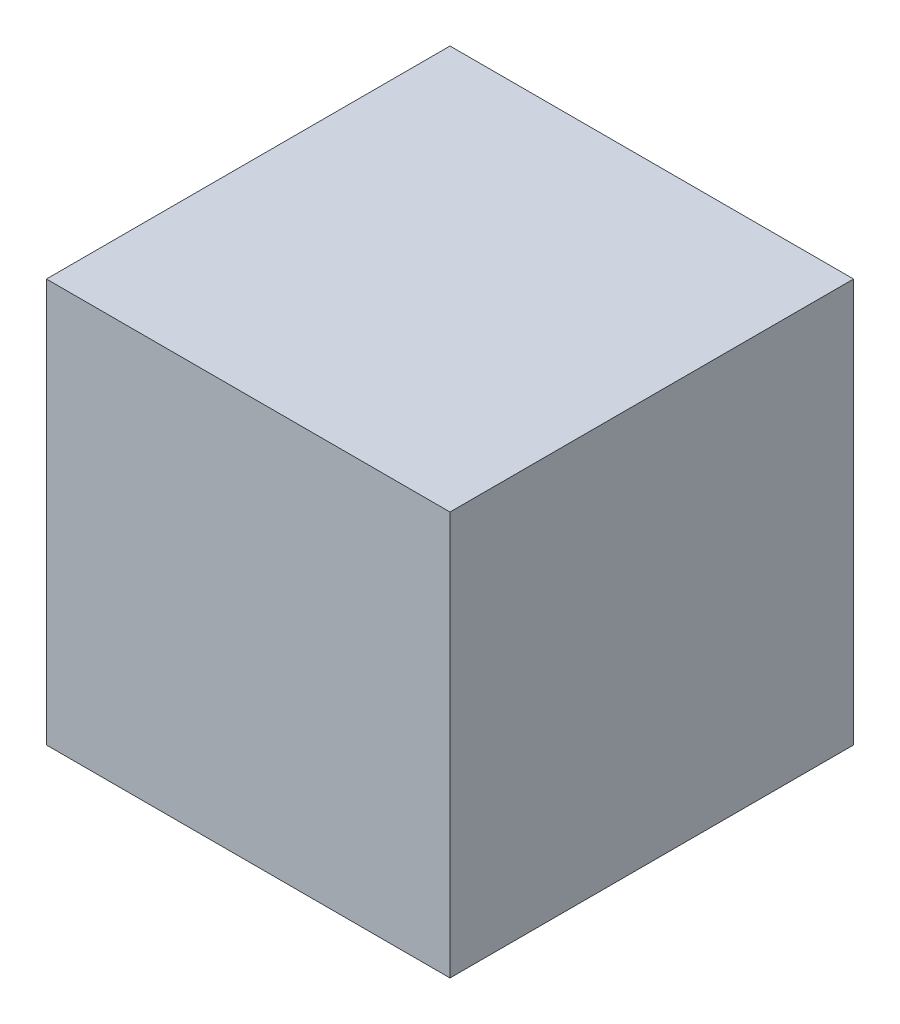
from build123d import *

# Parameters (mm, degrees)
BOSS_EXTRUDE1_DEPTH      = 15
BOSS_EXTRUDE1_DEPTH_BACK = 15
SKETCH1_W                = 30
SKETCH1_H                = 30


with BuildPart() as part:
    # Sketch1 → Boss-Extrude1 (new, two sides: drawn at the far end of the back side and taken through both)
    with BuildSketch(Plane(origin=(0, 0, 0), x_dir=(1, 0, 0), z_dir=(0, 1, 0)).offset(-BOSS_EXTRUDE1_DEPTH_BACK)):
        Rectangle(SKETCH1_W, SKETCH1_H)
    extrude(amount=BOSS_EXTRUDE1_DEPTH + BOSS_EXTRUDE1_DEPTH_BACK)


solid = part.part
